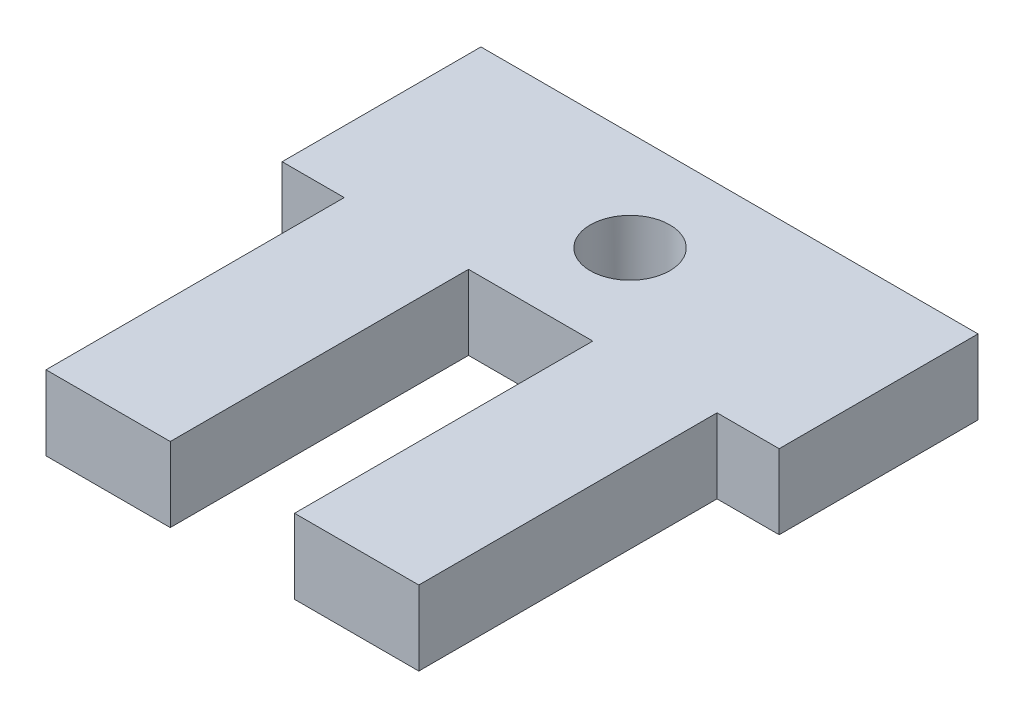
from build123d import *

# Parameters (mm, degrees)
SKETCH1_W               = 20
SKETCH1_H               = 20
BOSS_EXTRUDE1_DEPTH     = 3
SKETCH2_W               = 2.5
SKETCH2_H               = 12
CUT_EXTRUDE1_DEPTH      = 3
SKETCH3_R               = 1.6
CUT_EXTRUDE2_DEPTH      = 1
CUT_EXTRUDE2_DEPTH_BACK = 4
SKETCH4_W               = 5
SKETCH4_H               = 12
CUT_EXTRUDE3_DEPTH      = 1
CUT_EXTRUDE3_DEPTH_BACK = 4


with BuildPart() as part:
    # Sketch1 → Boss-Extrude1 (new body)
    with BuildSketch(Plane(origin=(0, 0, 0), x_dir=(1, 0, 0), z_dir=(0, 1, 0))):
        with Locations((10, 10)):
            Rectangle(SKETCH1_W, SKETCH1_H)
    extrude(amount=BOSS_EXTRUDE1_DEPTH)

    # Sketch2 → Cut-Extrude1 (cut)
    with BuildSketch(Plane(origin=(0, 3, 0), x_dir=(1, 0, 0), z_dir=(0, 1, 0))):
        with Locations((1.25, 6)):
            Rectangle(SKETCH2_W, SKETCH2_H)
    cut_extrude1 = extrude(amount=-CUT_EXTRUDE1_DEPTH, mode=Mode.SUBTRACT)

    # Mirror1: Cut-Extrude1 across plane
    add(cut_extrude1.mirror(Plane.ZY.offset(-10)), mode=Mode.SUBTRACT)

    # Sketch3 → Cut-Extrude2 (cut, two sides)
    with BuildSketch(Plane(origin=(0, 3, 0), x_dir=(1, 0, 0), z_dir=(0, 1, 0))) as cut_extrude2_sk:
        with Locations((10, 16)):
            Circle(SKETCH3_R)
    extrude(amount=CUT_EXTRUDE2_DEPTH, mode=Mode.SUBTRACT)
    extrude(cut_extrude2_sk.sketch, amount=-CUT_EXTRUDE2_DEPTH_BACK, mode=Mode.SUBTRACT)

    # Sketch4 → Cut-Extrude3 (cut, two sides)
    with BuildSketch(Plane(origin=(0, 3, 0), x_dir=(1, 0, 0), z_dir=(0, 1, 0))) as cut_extrude3_sk:
        with Locations((10, 6)):
            Rectangle(SKETCH4_W, SKETCH4_H)
    extrude(amount=CUT_EXTRUDE3_DEPTH, mode=Mode.SUBTRACT)
    extrude(cut_extrude3_sk.sketch, amount=-CUT_EXTRUDE3_DEPTH_BACK, mode=Mode.SUBTRACT)


solid = part.part
